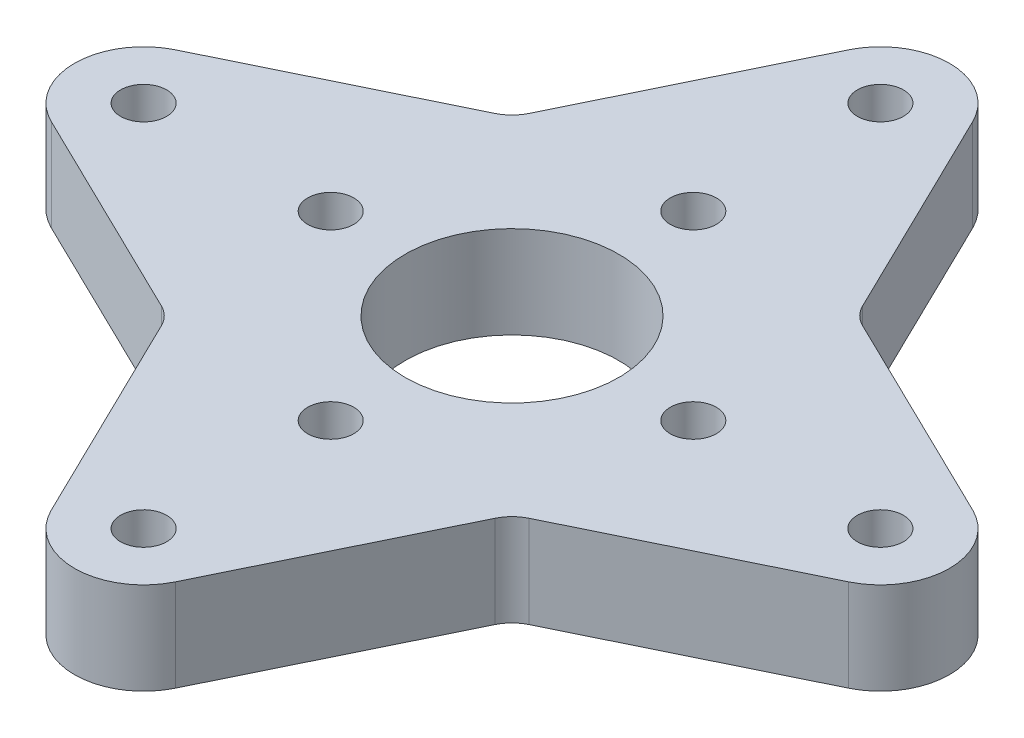
from build123d import *

# Parameters (mm, degrees)
SKETCH1_R           = 7.366
SKETCH1_R_2         = 1.5875
BOSS_EXTRUDE1_DEPTH = 6.35
CHAMFER1_SIZE       = 2.75


with BuildPart() as part:
    # Sketch1 → Boss-Extrude1 (new body)
    with BuildSketch(Plane(origin=(0, 0, 0), x_dir=(1, 0, 0), z_dir=(0, 1, 0))):
        with BuildLine():
            Line((4.281323883, 27.486066169), (11.500019866, 12.67082398))
            ThreePointArc((11.500019866, 12.67082398), (11.987341379, 11.987341379), (12.67082398, 11.500019866))
            Line((12.67082398, 11.500019866), (27.486066169, 4.281323883))
            ThreePointArc((27.486066169, 4.281323883), (30.1625, 0), (27.486066169, -4.281323883))
            Line((27.486066169, -4.281323883), (12.67082398, -11.500019866))
            ThreePointArc((12.67082398, -11.500019866), (11.987341379, -11.987341379), (11.500019866, -12.67082398))
            Line((11.500019866, -12.67082398), (4.281323883, -27.486066169))
            ThreePointArc((4.281323883, -27.486066169), (0, -30.1625), (-4.281323883, -27.486066169))
            Line((-4.281323883, -27.486066169), (-11.500019866, -12.67082398))
            ThreePointArc((-11.500019866, -12.67082398), (-11.987341379, -11.987341379), (-12.67082398, -11.500019866))
            Line((-12.67082398, -11.500019866), (-27.486066169, -4.281323883))
            ThreePointArc((-27.486066169, -4.281323883), (-30.1625, 0), (-27.486066169, 4.281323883))
            Line((-27.486066169, 4.281323883), (-12.67082398, 11.500019866))
            ThreePointArc((-12.67082398, 11.500019866), (-11.987341379, 11.987341379), (-11.500019866, 12.67082398))
            Line((-11.500019866, 12.67082398), (-4.281323883, 27.486066169))
            ThreePointArc((-4.281323883, 27.486066169), (0, 30.1625), (4.281323883, 27.486066169))
        make_face()
        Circle(SKETCH1_R, mode=Mode.SUBTRACT)
        with Locations((0, 25.4)):
            Circle(SKETCH1_R_2, mode=Mode.SUBTRACT)
        with Locations((0, 12.5)):
            Circle(SKETCH1_R_2, mode=Mode.SUBTRACT)
        with Locations((12.5, 0)):
            Circle(SKETCH1_R_2, mode=Mode.SUBTRACT)
        with Locations((25.4, 0)):
            Circle(SKETCH1_R_2, mode=Mode.SUBTRACT)
        with Locations((0, -25.4)):
            Circle(SKETCH1_R_2, mode=Mode.SUBTRACT)
        with Locations((0, -12.5)):
            Circle(SKETCH1_R_2, mode=Mode.SUBTRACT)
        with Locations((-12.5, 0)):
            Circle(SKETCH1_R_2, mode=Mode.SUBTRACT)
        with Locations((-25.4, 0)):
            Circle(SKETCH1_R_2, mode=Mode.SUBTRACT)
    extrude(amount=BOSS_EXTRUDE1_DEPTH)

    # Chamfer1
    chamfer1_edges = [part.edges().sort_by_distance(p)[0] for p in [
        (-1.5875, 0, -12.5),
        (10.9125, 0, 0),
        (-1.5875, 0, 12.5),
        (-14.0875, 0, 0),
    ]]
    chamfer(chamfer1_edges, length=CHAMFER1_SIZE)


solid = part.part
